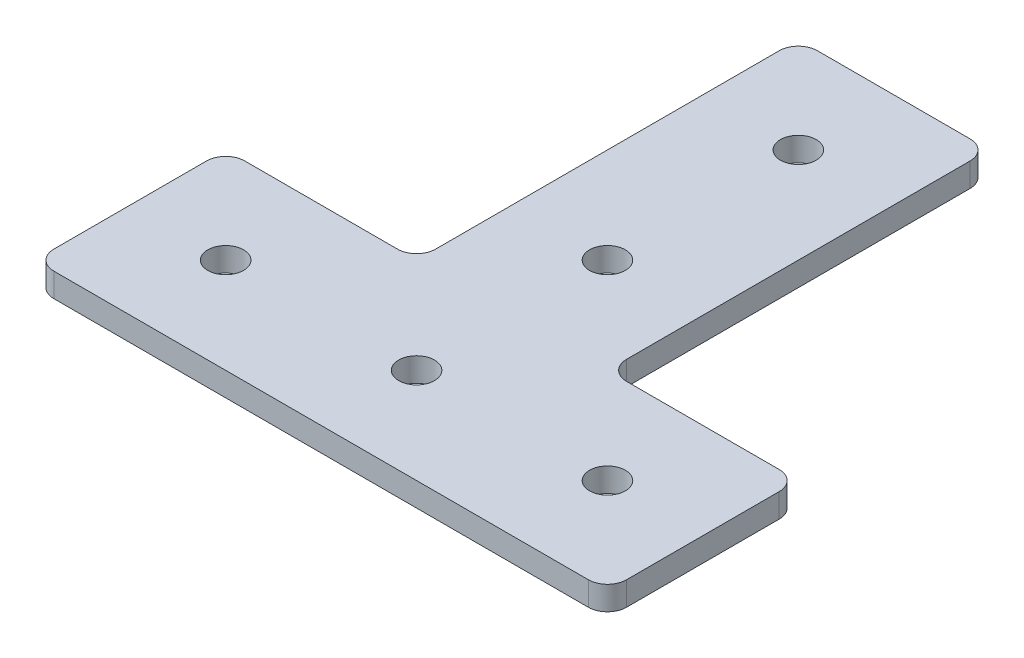
from build123d import *

# Parameters (mm, degrees)
SKETCH1_R           = 2.38125
BOSS_EXTRUDE1_DEPTH = 3.175


with BuildPart() as part:
    # Sketch1 → Boss-Extrude1 (new body)
    with BuildSketch(Plane(origin=(0, 0, 0), x_dir=(1, 0, 0), z_dir=(0, 1, 0))):
        with BuildLine():
            Line((18.720543933, 17.495711297), (39.040543933, 17.495711297))
            ThreePointArc((39.040543933, 17.495711297), (40.836595157, 16.751762521), (41.580543933, 14.955711297))
            Line((41.580543933, 14.955711297), (41.580543933, -5.364288703))
            ThreePointArc((41.580543933, -5.364288703), (40.836595157, -7.160339927), (39.040543933, -7.904288703))
            Line((39.040543933, -7.904288703), (-32.079456067, -7.904288703))
            ThreePointArc((-32.079456067, -7.904288703), (-33.875507291, -7.160339927), (-34.619456067, -5.364288703))
            Line((-34.619456067, -5.364288703), (-34.619456067, 14.955711297))
            ThreePointArc((-34.619456067, 14.955711297), (-33.875507291, 16.751762521), (-32.079456067, 17.495711297))
            Line((-32.079456067, 17.495711297), (-11.759456067, 17.495711297))
            ThreePointArc((-11.759456067, 17.495711297), (-9.963404843, 18.239660073), (-9.219456067, 20.035711297))
            Line((-9.219456067, 20.035711297), (-9.219456067, 65.755711297))
            ThreePointArc((-9.219456067, 65.755711297), (-8.475507291, 67.551762521), (-6.679456067, 68.295711297))
            Line((-6.679456067, 68.295711297), (13.640543933, 68.295711297))
            ThreePointArc((13.640543933, 68.295711297), (15.436595157, 67.551762521), (16.180543933, 65.755711297))
            Line((16.180543933, 65.755711297), (16.180543933, 20.035711297))
            ThreePointArc((16.180543933, 20.035711297), (16.924492709, 18.239660073), (18.720543933, 17.495711297))
        make_face()
        with Locations((3.480543933, 4.795711297)):
            Circle(SKETCH1_R, mode=Mode.SUBTRACT)
        with Locations((-21.919456067, 4.795711297)):
            Circle(SKETCH1_R, mode=Mode.SUBTRACT)
        with Locations((28.880543933, 4.795711297)):
            Circle(SKETCH1_R, mode=Mode.SUBTRACT)
        with Locations((3.480543933, 30.195711297)):
            Circle(SKETCH1_R, mode=Mode.SUBTRACT)
        with Locations((3.480543933, 55.595711297)):
            Circle(SKETCH1_R, mode=Mode.SUBTRACT)
    extrude(amount=BOSS_EXTRUDE1_DEPTH)


solid = part.part
